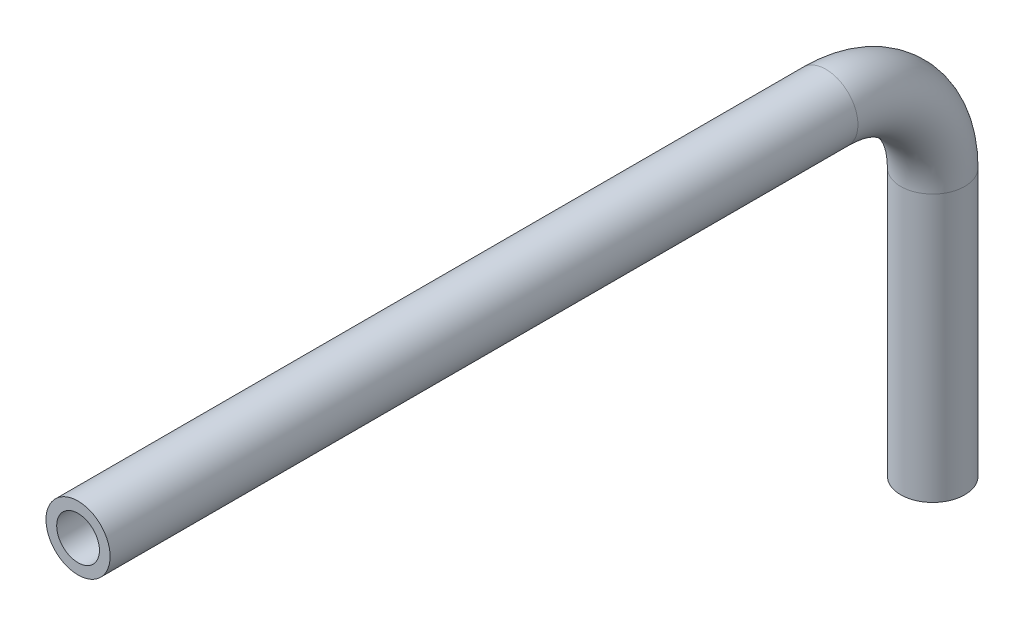
from build123d import *

# Parameters (mm, degrees)
SWEEP_THIN1_PROFILE_R   = 30
SWEEP_THIN1_PROFILE_R_2 = 20


with BuildPart() as part:
    # Sweep-Thin1: sweep along a path in Sketch1
    with BuildLine(Plane(origin=(0, 0, 0), x_dir=(0, 0, -1), z_dir=(1, 0, 0))) as sweep_thin1_path:
        Line((0, 0), (700, 0))
        ThreePointArc((700, 0), (770.710678119, -29.289321881), (800, -100))
        Line((800, -100), (800, -350))
    # Sweep-Thin1 profile (on start of the path) → Sweep-Thin1 (sweep)
    with BuildSketch(Plane(origin=(0, 0, 0), x_dir=(-1, 0, 0), z_dir=(0, 0, -1))):
        Circle(SWEEP_THIN1_PROFILE_R)
        Circle(SWEEP_THIN1_PROFILE_R_2, mode=Mode.SUBTRACT)
    sweep(path=sweep_thin1_path.line)


solid = part.part
